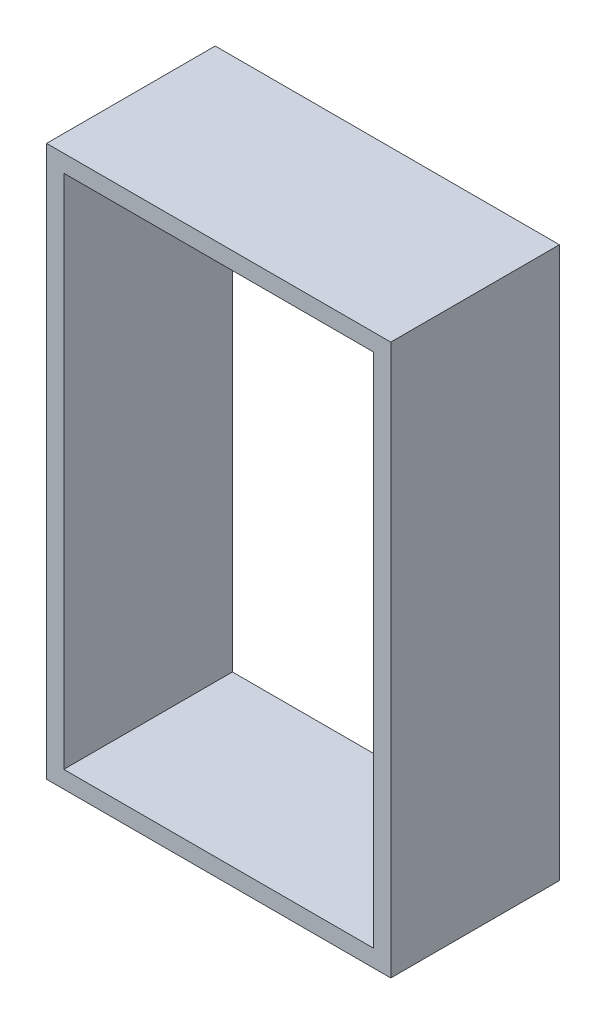
from build123d import *

# Parameters (mm, degrees)
SKETCH1_W           = 127
SKETCH1_H           = 203.2
SKETCH1_W_2         = 114.3
SKETCH1_H_2         = 190.5
BOSS_EXTRUDE1_DEPTH = 62.23


with BuildPart() as part:
    # Sketch1 → Boss-Extrude1 (new body)
    with BuildSketch(Plane.XY):
        with Locations((63.5, 101.6)):
            Rectangle(SKETCH1_W, SKETCH1_H)
        with Locations((63.5, 101.6)):
            Rectangle(SKETCH1_W_2, SKETCH1_H_2, mode=Mode.SUBTRACT)
    extrude(amount=BOSS_EXTRUDE1_DEPTH)


solid = part.part
